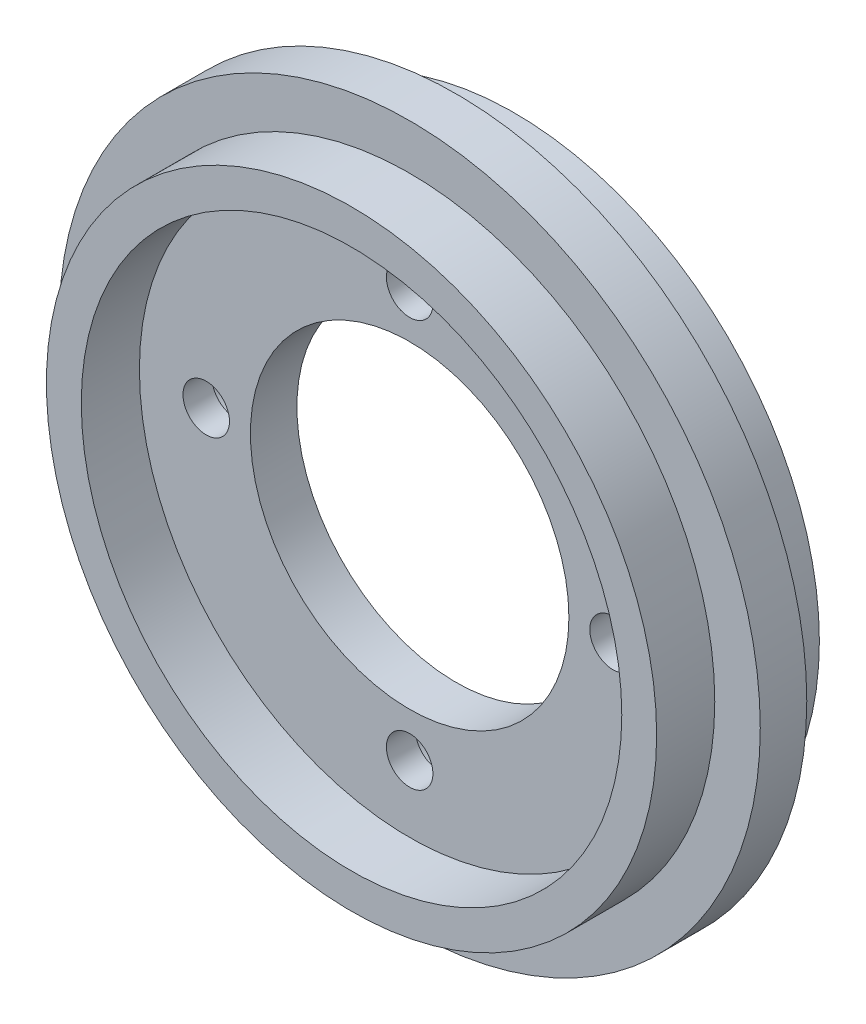
from build123d import *

# Parameters (mm, degrees)
SALIENTE_EXTRUIR1_DEPTH      = 2
SALIENTE_EXTRUIR1_DEPTH_BACK = 2
CROQUIS1_R                   = 30.165
CROQUIS1_R_2                 = 13.7
CROQUIS1_R_3                 = 2
CROQUIS3_R                   = 26.25
CROQUIS3_R_2                 = 23.25
SALIENTE_EXTRUIR2_DEPTH      = 5
CROQUIS4_R                   = 3.5
CORTAR_EXTRUIR1_DEPTH        = 1.5


with BuildPart() as part:
    # Croquis1 → Saliente-Extruir1 (new, two sides: drawn at the far end of the back side and taken through both)
    with BuildSketch(Plane.XY.offset(-SALIENTE_EXTRUIR1_DEPTH_BACK)):
        Circle(CROQUIS1_R)
        Circle(CROQUIS1_R_2, mode=Mode.SUBTRACT)
        with Locations((0, 17.5)):
            Circle(CROQUIS1_R_3, mode=Mode.SUBTRACT)
        with Locations((17.5, 0)):
            Circle(CROQUIS1_R_3, mode=Mode.SUBTRACT)
        with Locations((-17.5, 0)):
            Circle(CROQUIS1_R_3, mode=Mode.SUBTRACT)
        with Locations((0, -17.5)):
            Circle(CROQUIS1_R_3, mode=Mode.SUBTRACT)
    extrude(amount=SALIENTE_EXTRUIR1_DEPTH + SALIENTE_EXTRUIR1_DEPTH_BACK)

    # Croquis3 → Saliente-Extruir2 (add)
    with BuildSketch(Plane.XY.offset(2)):
        Circle(CROQUIS3_R)
        Circle(CROQUIS3_R_2, mode=Mode.SUBTRACT)
    saliente_extruir2 = extrude(amount=SALIENTE_EXTRUIR2_DEPTH)

    # Croquis4 → Cortar-Extruir1 (cut)
    with BuildSketch(Plane(origin=(0, 0, -2), x_dir=(-1, 0, 0), z_dir=(0, 0, -1))):
        with Locations((0, 17.5)):
            Circle(CROQUIS4_R)
        with Locations((17.5, 0)):
            Circle(CROQUIS4_R)
        with Locations((-17.5, 0)):
            Circle(CROQUIS4_R)
        with Locations((0, -17.5)):
            Circle(CROQUIS4_R)
    extrude(amount=-CORTAR_EXTRUIR1_DEPTH, mode=Mode.SUBTRACT)

    # Simetría1: Saliente-Extruir2 across plane
    add(saliente_extruir2.mirror(Plane.XY))


solid = part.part
